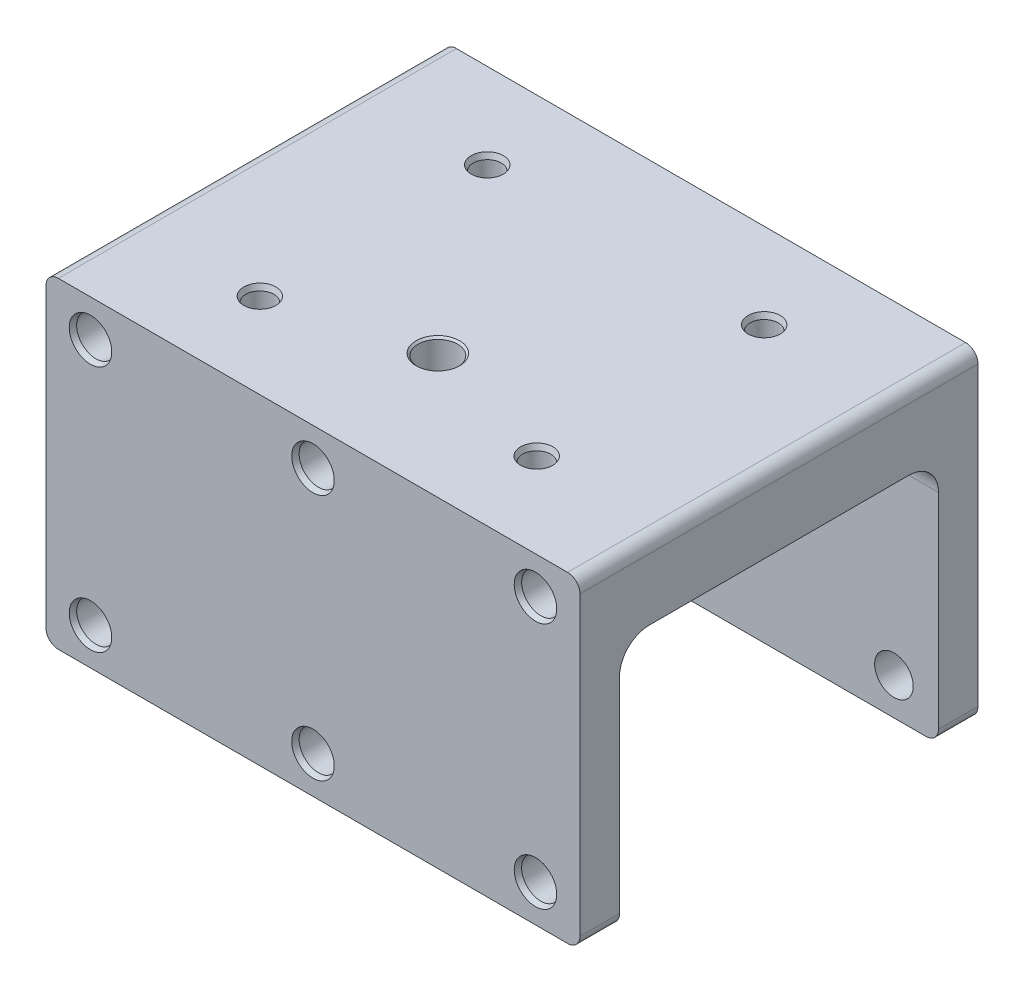
from build123d import *

# Parameters (mm, degrees)
SKETCH1_W             = 108
SKETCH1_H             = 80.5
BOSS_EXTRUDE1_DEPTH   = 15
SKETCH2_R             = 3.9
CUT_EXTRUDE1_DEPTH    = 7
SKETCH3_W             = 108
SKETCH3_H             = 50
SKETCH3_R             = 3.9
BOSS_EXTRUDE2_DEPTH   = 8
CHAMFER1_SIZE         = 0.4
CHAMFER1_SIZE2        = 1.098990968
CHAMFER1_PART_2_SIZE  = 0.4
CHAMFER1_PART_2_SIZE2 = 1.098990968
FILLET1_R             = 2.5
FILLET2_R             = 6
SKETCH4_R             = 2.85
CUT_EXTRUDE2_DEPTH    = 11
CHAMFER2_SIZE         = 0.4
CHAMFER2_SIZE2        = 1.098990968
SKETCH5_R             = 4
CUT_EXTRUDE3_DEPTH    = 66
CHAMFER3_SIZE         = 0.4


with BuildPart() as part:
    # Sketch1 → Boss-Extrude1 (new body)
    with BuildSketch(Plane(origin=(0, 0, 0), x_dir=(1, 0, 0), z_dir=(0, 1, 0))):
        with Locations((54, 40.25)):
            Rectangle(SKETCH1_W, SKETCH1_H)
    extrude(amount=BOSS_EXTRUDE1_DEPTH)

    # Sketch2 → Cut-Extrude1 (cut)
    with BuildSketch(Plane.XY):
        with Locations((9, 7.5)):
            Circle(SKETCH2_R)
        with Locations((99, 7.5)):
            Circle(SKETCH2_R)
        with Locations((54, 7.5)):
            Circle(SKETCH2_R)
    cut_extrude1 = extrude(amount=-CUT_EXTRUDE1_DEPTH, mode=Mode.SUBTRACT)

    # Sketch3 → Boss-Extrude2 (add)
    with BuildSketch(Plane.XY):
        with Locations((54, -25)):
            Rectangle(SKETCH3_W, SKETCH3_H)
        with Locations((99, -42.5)):
            Circle(SKETCH3_R, mode=Mode.SUBTRACT)
        with Locations((54, -42.5)):
            Circle(SKETCH3_R, mode=Mode.SUBTRACT)
        with Locations((9, -42.5)):
            Circle(SKETCH3_R, mode=Mode.SUBTRACT)
    boss_extrude2 = extrude(amount=-BOSS_EXTRUDE2_DEPTH)

    # Mirror1: Cut-Extrude1, Boss-Extrude2 across plane
    add(cut_extrude1.mirror(Plane.XY.offset(-40.25)), mode=Mode.SUBTRACT)
    add(boss_extrude2.mirror(Plane.XY.offset(-40.25)))

    # Chamfer1
    chamfer1_edges = [part.edges().sort_by_distance(p)[0] for p in [
        (5.1, 7.5, 0),
        (95.1, 7.5, 0),
        (50.1, 7.5, 0),
        (95.1, -42.5, 0),
        (50.1, -42.5, 0),
        (5.1, -42.5, 0),
    ]]
    chamfer1_side = [part.faces().sort_by_distance(p)[0] for p in [
        (54, -17.5, 0),
    ]]
    chamfer(chamfer1_edges, length=CHAMFER1_SIZE, length2=CHAMFER1_SIZE2, reference=chamfer1_side[0])

    # Chamfer1 part 2
    chamfer1_part_2_edges = [part.edges().sort_by_distance(p)[0] for p in [
        (5.1, 7.5, -80.5),
        (95.1, 7.5, -80.5),
        (50.1, 7.5, -80.5),
        (50.1, -42.5, -80.5),
        (95.1, -42.5, -80.5),
        (5.1, -42.5, -80.5),
    ]]
    chamfer1_part_2_side = [part.faces().sort_by_distance(p)[0] for p in [
        (54, -17.5, -80.5),
    ]]
    chamfer(chamfer1_part_2_edges, length=CHAMFER1_PART_2_SIZE, length2=CHAMFER1_PART_2_SIZE2, reference=chamfer1_part_2_side[0])

    # Fillet1
    fillet1_edges = [part.edges().sort_by_distance(p)[0] for p in [
        (108, 15, -40.25),
        (0, -50, -4),
        (108, -50, -4),
        (0, 15, -40.25),
        (0, -50, -76.5),
        (108, -50, -76.5),
    ]]
    fillet(fillet1_edges, radius=FILLET1_R)

    # Fillet2
    fillet2_edges = [part.edges().sort_by_distance(p)[0] for p in [
        (54, 0, -8),
        (54, 0, -72.5),
    ]]
    fillet(fillet2_edges, radius=FILLET2_R)

    # Sketch4 → Cut-Extrude2 (cut)
    with BuildSketch(Plane(origin=(0, 15, 0), x_dir=(1, 0, 0), z_dir=(0, 1, 0))):
        with Locations((82, 17.25)):
            Circle(SKETCH4_R)
        with Locations((26, 17.25)):
            Circle(SKETCH4_R)
        with Locations((26, 63.25)):
            Circle(SKETCH4_R)
        with Locations((82, 63.25)):
            Circle(SKETCH4_R)
    extrude(amount=-CUT_EXTRUDE2_DEPTH, mode=Mode.SUBTRACT)

    # Chamfer2
    chamfer2_edges = [part.edges().sort_by_distance(p)[0] for p in [
        (79.15, 15, -63.25),
        (23.15, 15, -63.25),
        (23.15, 15, -17.25),
        (79.15, 15, -17.25),
    ]]
    chamfer2_side = [part.faces().sort_by_distance(p)[0] for p in [
        (54, 15, -40.25),
    ]]
    chamfer(chamfer2_edges, length=CHAMFER2_SIZE, length2=CHAMFER2_SIZE2, reference=chamfer2_side[0])

    # Sketch5 → Cut-Extrude3 (cut, through all)
    with BuildSketch(Plane(origin=(0, 15, 0), x_dir=(1, 0, 0), z_dir=(0, 1, 0))):
        with Locations((54, 25.25)):
            Circle(SKETCH5_R)
    extrude(amount=-CUT_EXTRUDE3_DEPTH, mode=Mode.SUBTRACT)

    # Chamfer3
    chamfer3_edges = [part.edges().sort_by_distance(p)[0] for p in [
        (50, 15, -25.25),
    ]]
    chamfer(chamfer3_edges, length=CHAMFER3_SIZE)


solid = part.part
